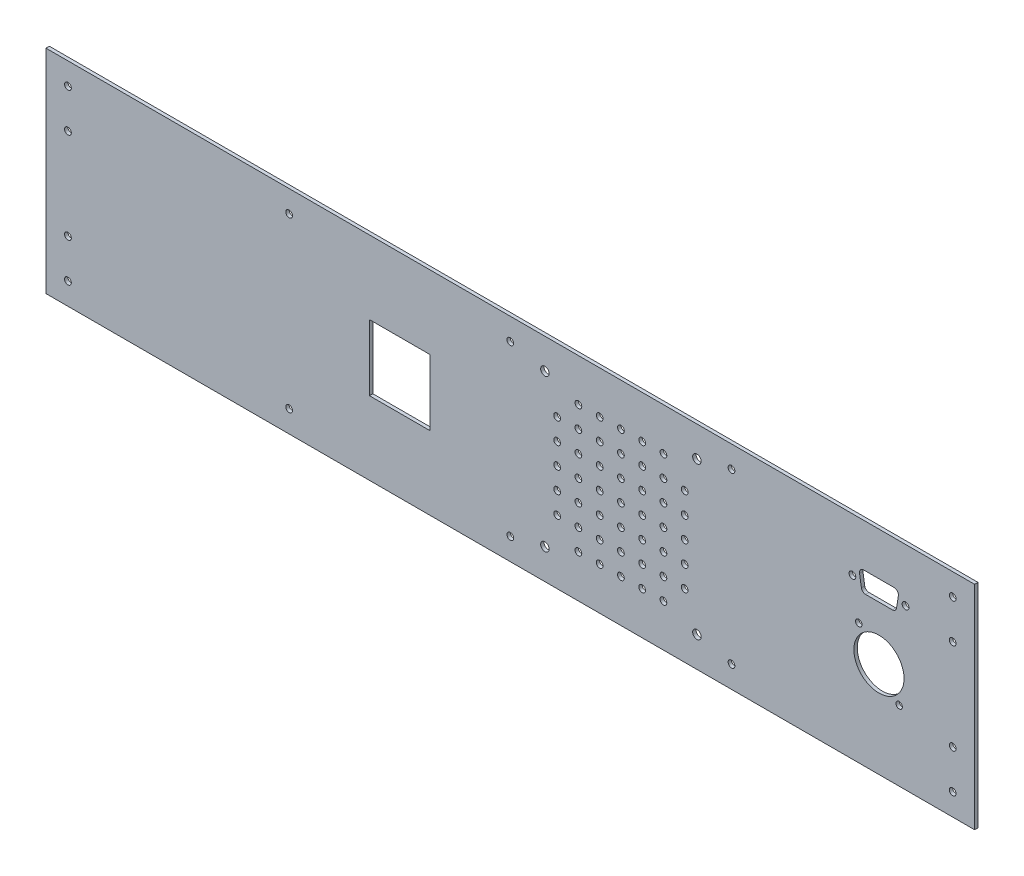
from build123d import *

# Parameters (mm, degrees)
ESQUISSE1_W             = 436.825
ESQUISSE1_H             = 100
BOSS_EXTRU_1_DEPTH      = 1.5875
ENL_V_MAT_EXTRU_1_REACH = 3.587
ESQUISSE2_R             = 1.5875
ENL_V_MAT_EXTRU_2_REACH = 3.587
ESQUISSE3_W             = 28.5
ESQUISSE3_H             = 31
ESQUISSE4_R             = 2
ESQUISSE4_R_2           = 1.5875
ENL_V_MAT_EXTRU_3_DEPTH = 1.5875
ENL_V_MAT_EXTRU_4_REACH = 3.587
ESQUISSE5_R             = 11.8
ESQUISSE5_R_2           = 1.53125
ESQUISSE5_R_3           = 1.5875
CONG_1_R                = 2


with BuildPart() as part:
    # Esquisse1 → Boss.-Extru.1 (new body)
    with BuildSketch(Plane.XY):
        with Locations((98.31082913, 31.147540984)):
            Rectangle(ESQUISSE1_W, ESQUISSE1_H)
    extrude(amount=BOSS_EXTRU_1_DEPTH)

    # Esquisse2 → Enlèv. mat.-Extru.1 (cut, up to next)
    with BuildSketch(Plane(origin=(0, 0, 0), x_dir=(-1, 0, 0), z_dir=(0, 0, -1)), mode=Mode.PRIVATE) as enl_v_mat_extru_1_sk1:
        with Locations((-306.40457913, 9.727540984)):
            Circle(ESQUISSE2_R)
    enl_v_mat_extru_1_tool1 = extrude(enl_v_mat_extru_1_sk1.sketch, amount=-ENL_V_MAT_EXTRU_1_REACH, mode=Mode.PRIVATE) & part.part
    add(enl_v_mat_extru_1_tool1.solids().sort_by_distance((306.404579, 9.727541, 0))[0], mode=Mode.SUBTRACT)
    # Esquisse2 → Enlèv. mat.-Extru.1 (cut, up to next)
    with BuildSketch(Plane(origin=(0, 0, 0), x_dir=(-1, 0, 0), z_dir=(0, 0, -1)), mode=Mode.PRIVATE) as enl_v_mat_extru_1_sk2:
        with Locations((-306.40457913, -8.533709016)):
            Circle(ESQUISSE2_R)
    enl_v_mat_extru_1_tool2 = extrude(enl_v_mat_extru_1_sk2.sketch, amount=-ENL_V_MAT_EXTRU_1_REACH, mode=Mode.PRIVATE) & part.part
    add(enl_v_mat_extru_1_tool2.solids().sort_by_distance((306.404579, -8.533709, 0))[0], mode=Mode.SUBTRACT)
    # Esquisse2 → Enlèv. mat.-Extru.1 (cut, up to next)
    with BuildSketch(Plane(origin=(0, 0, 0), x_dir=(-1, 0, 0), z_dir=(0, 0, -1)), mode=Mode.PRIVATE) as enl_v_mat_extru_1_sk3:
        with Locations((-98.31082913, -8.533709016)):
            Circle(ESQUISSE2_R)
    enl_v_mat_extru_1_tool3 = extrude(enl_v_mat_extru_1_sk3.sketch, amount=-ENL_V_MAT_EXTRU_1_REACH, mode=Mode.PRIVATE) & part.part
    add(enl_v_mat_extru_1_tool3.solids().sort_by_distance((98.310829, -8.533709, 0))[0], mode=Mode.SUBTRACT)
    # Esquisse2 → Enlèv. mat.-Extru.1 (cut, up to next)
    with BuildSketch(Plane(origin=(0, 0, 0), x_dir=(-1, 0, 0), z_dir=(0, 0, -1)), mode=Mode.PRIVATE) as enl_v_mat_extru_1_sk4:
        with Locations((-202.35770413, -8.533709016)):
            Circle(ESQUISSE2_R)
    enl_v_mat_extru_1_tool4 = extrude(enl_v_mat_extru_1_sk4.sketch, amount=-ENL_V_MAT_EXTRU_1_REACH, mode=Mode.PRIVATE) & part.part
    add(enl_v_mat_extru_1_tool4.solids().sort_by_distance((202.357704, -8.533709, 0))[0], mode=Mode.SUBTRACT)
    # Esquisse2 → Enlèv. mat.-Extru.1 (cut, up to next)
    with BuildSketch(Plane(origin=(0, 0, 0), x_dir=(-1, 0, 0), z_dir=(0, 0, -1)), mode=Mode.PRIVATE) as enl_v_mat_extru_1_sk5:
        with Locations((5.73604587, -8.533709016)):
            Circle(ESQUISSE2_R)
    enl_v_mat_extru_1_tool5 = extrude(enl_v_mat_extru_1_sk5.sketch, amount=-ENL_V_MAT_EXTRU_1_REACH, mode=Mode.PRIVATE) & part.part
    add(enl_v_mat_extru_1_tool5.solids().sort_by_distance((-5.736046, -8.533709, 0))[0], mode=Mode.SUBTRACT)
    # Esquisse2 → Enlèv. mat.-Extru.1 (cut, up to next)
    with BuildSketch(Plane(origin=(0, 0, 0), x_dir=(-1, 0, 0), z_dir=(0, 0, -1)), mode=Mode.PRIVATE) as enl_v_mat_extru_1_sk6:
        with Locations((109.78292087, -8.533709016)):
            Circle(ESQUISSE2_R)
    enl_v_mat_extru_1_tool6 = extrude(enl_v_mat_extru_1_sk6.sketch, amount=-ENL_V_MAT_EXTRU_1_REACH, mode=Mode.PRIVATE) & part.part
    add(enl_v_mat_extru_1_tool6.solids().sort_by_distance((-109.782921, -8.533709, 0))[0], mode=Mode.SUBTRACT)
    # Esquisse2 → Enlèv. mat.-Extru.1 (cut, up to next)
    with BuildSketch(Plane(origin=(0, 0, 0), x_dir=(-1, 0, 0), z_dir=(0, 0, -1)), mode=Mode.PRIVATE) as enl_v_mat_extru_1_sk7:
        with Locations((109.78292087, 9.727540984)):
            Circle(ESQUISSE2_R)
    enl_v_mat_extru_1_tool7 = extrude(enl_v_mat_extru_1_sk7.sketch, amount=-ENL_V_MAT_EXTRU_1_REACH, mode=Mode.PRIVATE) & part.part
    add(enl_v_mat_extru_1_tool7.solids().sort_by_distance((-109.782921, 9.727541, 0))[0], mode=Mode.SUBTRACT)
    # Esquisse2 → Enlèv. mat.-Extru.1 (cut, up to next)
    with BuildSketch(Plane(origin=(0, 0, 0), x_dir=(-1, 0, 0), z_dir=(0, 0, -1)), mode=Mode.PRIVATE) as enl_v_mat_extru_1_sk8:
        with Locations((109.78292087, 52.567540984)):
            Circle(ESQUISSE2_R)
    enl_v_mat_extru_1_tool8 = extrude(enl_v_mat_extru_1_sk8.sketch, amount=-ENL_V_MAT_EXTRU_1_REACH, mode=Mode.PRIVATE) & part.part
    add(enl_v_mat_extru_1_tool8.solids().sort_by_distance((-109.782921, 52.567541, 0))[0], mode=Mode.SUBTRACT)
    # Esquisse2 → Enlèv. mat.-Extru.1 (cut, up to next)
    with BuildSketch(Plane(origin=(0, 0, 0), x_dir=(-1, 0, 0), z_dir=(0, 0, -1)), mode=Mode.PRIVATE) as enl_v_mat_extru_1_sk9:
        with Locations((109.78292087, 70.828790984)):
            Circle(ESQUISSE2_R)
    enl_v_mat_extru_1_tool9 = extrude(enl_v_mat_extru_1_sk9.sketch, amount=-ENL_V_MAT_EXTRU_1_REACH, mode=Mode.PRIVATE) & part.part
    add(enl_v_mat_extru_1_tool9.solids().sort_by_distance((-109.782921, 70.828791, 0))[0], mode=Mode.SUBTRACT)
    # Esquisse2 → Enlèv. mat.-Extru.1 (cut, up to next)
    with BuildSketch(Plane(origin=(0, 0, 0), x_dir=(-1, 0, 0), z_dir=(0, 0, -1)), mode=Mode.PRIVATE) as enl_v_mat_extru_1_sk10:
        with Locations((5.73604587, 70.828790984)):
            Circle(ESQUISSE2_R)
    enl_v_mat_extru_1_tool10 = extrude(enl_v_mat_extru_1_sk10.sketch, amount=-ENL_V_MAT_EXTRU_1_REACH, mode=Mode.PRIVATE) & part.part
    add(enl_v_mat_extru_1_tool10.solids().sort_by_distance((-5.736046, 70.828791, 0))[0], mode=Mode.SUBTRACT)
    # Esquisse2 → Enlèv. mat.-Extru.1 (cut, up to next)
    with BuildSketch(Plane(origin=(0, 0, 0), x_dir=(-1, 0, 0), z_dir=(0, 0, -1)), mode=Mode.PRIVATE) as enl_v_mat_extru_1_sk11:
        with Locations((-98.31082913, 70.828790984)):
            Circle(ESQUISSE2_R)
    enl_v_mat_extru_1_tool11 = extrude(enl_v_mat_extru_1_sk11.sketch, amount=-ENL_V_MAT_EXTRU_1_REACH, mode=Mode.PRIVATE) & part.part
    add(enl_v_mat_extru_1_tool11.solids().sort_by_distance((98.310829, 70.828791, 0))[0], mode=Mode.SUBTRACT)
    # Esquisse2 → Enlèv. mat.-Extru.1 (cut, up to next)
    with BuildSketch(Plane(origin=(0, 0, 0), x_dir=(-1, 0, 0), z_dir=(0, 0, -1)), mode=Mode.PRIVATE) as enl_v_mat_extru_1_sk12:
        with Locations((-202.35770413, 70.828790984)):
            Circle(ESQUISSE2_R)
    enl_v_mat_extru_1_tool12 = extrude(enl_v_mat_extru_1_sk12.sketch, amount=-ENL_V_MAT_EXTRU_1_REACH, mode=Mode.PRIVATE) & part.part
    add(enl_v_mat_extru_1_tool12.solids().sort_by_distance((202.357704, 70.828791, 0))[0], mode=Mode.SUBTRACT)
    # Esquisse2 → Enlèv. mat.-Extru.1 (cut, up to next)
    with BuildSketch(Plane(origin=(0, 0, 0), x_dir=(-1, 0, 0), z_dir=(0, 0, -1)), mode=Mode.PRIVATE) as enl_v_mat_extru_1_sk13:
        with Locations((-306.40457913, 70.828790984)):
            Circle(ESQUISSE2_R)
    enl_v_mat_extru_1_tool13 = extrude(enl_v_mat_extru_1_sk13.sketch, amount=-ENL_V_MAT_EXTRU_1_REACH, mode=Mode.PRIVATE) & part.part
    add(enl_v_mat_extru_1_tool13.solids().sort_by_distance((306.404579, 70.828791, 0))[0], mode=Mode.SUBTRACT)
    # Esquisse2 → Enlèv. mat.-Extru.1 (cut, up to next)
    with BuildSketch(Plane(origin=(0, 0, 0), x_dir=(-1, 0, 0), z_dir=(0, 0, -1)), mode=Mode.PRIVATE) as enl_v_mat_extru_1_sk14:
        with Locations((-306.40457913, 52.567540984)):
            Circle(ESQUISSE2_R)
    enl_v_mat_extru_1_tool14 = extrude(enl_v_mat_extru_1_sk14.sketch, amount=-ENL_V_MAT_EXTRU_1_REACH, mode=Mode.PRIVATE) & part.part
    add(enl_v_mat_extru_1_tool14.solids().sort_by_distance((306.404579, 52.567541, 0))[0], mode=Mode.SUBTRACT)

    # Esquisse3 → Enlèv. mat.-Extru.2 (cut, up to next)
    with BuildSketch(Plane(origin=(0, 0, 0), x_dir=(-1, 0, 0), z_dir=(0, 0, -1)), mode=Mode.PRIVATE) as enl_v_mat_extru_2_sk1:
        with Locations((-46.28739163, 31.147540984)):
            Rectangle(ESQUISSE3_W, ESQUISSE3_H)
    enl_v_mat_extru_2_tool1 = extrude(enl_v_mat_extru_2_sk1.sketch, amount=-ENL_V_MAT_EXTRU_2_REACH, mode=Mode.PRIVATE) & part.part
    add(enl_v_mat_extru_2_tool1.solids().sort_by_distance((46.287392, 31.147541, 0))[0], mode=Mode.SUBTRACT)

    # Esquisse4 → Enlèv. mat.-Extru.3 (cut)
    with BuildSketch(Plane(origin=(0, 0, 0), x_dir=(-1, 0, 0), z_dir=(0, 0, -1))):
        with Locations((-186.08426663, 66.897540984)):
            Circle(ESQUISSE4_R)
        with Locations((-114.58426663, 66.897540984)):
            Circle(ESQUISSE4_R)
        with Locations((-114.58426663, -4.602459016)):
            Circle(ESQUISSE4_R)
        with Locations((-186.08426663, -4.602459016)):
            Circle(ESQUISSE4_R)
        with Locations((-150.33426663, 31.147540984)):
            Circle(ESQUISSE4_R_2)
        with Locations((-140.33426663, 31.147540984)):
            Circle(ESQUISSE4_R_2)
        with Locations((-130.33426663, 31.147540984)):
            Circle(ESQUISSE4_R_2)
        with Locations((-120.33426663, 31.147540984)):
            Circle(ESQUISSE4_R_2)
        with Locations((-140.33426663, 41.147540984)):
            Circle(ESQUISSE4_R_2)
        with Locations((-130.33426663, 41.147540984)):
            Circle(ESQUISSE4_R_2)
        with Locations((-120.33426663, 41.147540984)):
            Circle(ESQUISSE4_R_2)
        with Locations((-140.33426663, 51.147540984)):
            Circle(ESQUISSE4_R_2)
        with Locations((-130.33426663, 51.147540984)):
            Circle(ESQUISSE4_R_2)
        with Locations((-120.33426663, 51.147540984)):
            Circle(ESQUISSE4_R_2)
        with Locations((-140.33426663, 61.147540984)):
            Circle(ESQUISSE4_R_2)
        with Locations((-130.33426663, 61.147540984)):
            Circle(ESQUISSE4_R_2)
        with Locations((-160.33426663, 31.147540984)):
            Circle(ESQUISSE4_R_2)
        with Locations((-170.33426663, 31.147540984)):
            Circle(ESQUISSE4_R_2)
        with Locations((-180.33426663, 31.147540984)):
            Circle(ESQUISSE4_R_2)
        with Locations((-160.33426663, 41.147540984)):
            Circle(ESQUISSE4_R_2)
        with Locations((-170.33426663, 41.147540984)):
            Circle(ESQUISSE4_R_2)
        with Locations((-180.33426663, 41.147540984)):
            Circle(ESQUISSE4_R_2)
        with Locations((-160.33426663, 51.147540984)):
            Circle(ESQUISSE4_R_2)
        with Locations((-170.33426663, 51.147540984)):
            Circle(ESQUISSE4_R_2)
        with Locations((-180.33426663, 51.147540984)):
            Circle(ESQUISSE4_R_2)
        with Locations((-160.33426663, 61.147540984)):
            Circle(ESQUISSE4_R_2)
        with Locations((-170.33426663, 61.147540984)):
            Circle(ESQUISSE4_R_2)
        with Locations((-150.33426663, 41.147540984)):
            Circle(ESQUISSE4_R_2)
        with Locations((-150.33426663, 51.147540984)):
            Circle(ESQUISSE4_R_2)
        with Locations((-150.33426663, 61.147540984)):
            Circle(ESQUISSE4_R_2)
        with Locations((-150.33426663, 21.147540984)):
            Circle(ESQUISSE4_R_2)
        with Locations((-140.33426663, 21.147540984)):
            Circle(ESQUISSE4_R_2)
        with Locations((-130.33426663, 21.147540984)):
            Circle(ESQUISSE4_R_2)
        with Locations((-120.33426663, 21.147540984)):
            Circle(ESQUISSE4_R_2)
        with Locations((-140.33426663, 11.147540984)):
            Circle(ESQUISSE4_R_2)
        with Locations((-130.33426663, 11.147540984)):
            Circle(ESQUISSE4_R_2)
        with Locations((-120.33426663, 11.147540984)):
            Circle(ESQUISSE4_R_2)
        with Locations((-140.33426663, 1.147540984)):
            Circle(ESQUISSE4_R_2)
        with Locations((-130.33426663, 1.147540984)):
            Circle(ESQUISSE4_R_2)
        with Locations((-160.33426663, 21.147540984)):
            Circle(ESQUISSE4_R_2)
        with Locations((-170.33426663, 21.147540984)):
            Circle(ESQUISSE4_R_2)
        with Locations((-180.33426663, 21.147540984)):
            Circle(ESQUISSE4_R_2)
        with Locations((-160.33426663, 11.147540984)):
            Circle(ESQUISSE4_R_2)
        with Locations((-170.33426663, 11.147540984)):
            Circle(ESQUISSE4_R_2)
        with Locations((-180.33426663, 11.147540984)):
            Circle(ESQUISSE4_R_2)
        with Locations((-160.33426663, 1.147540984)):
            Circle(ESQUISSE4_R_2)
        with Locations((-170.33426663, 1.147540984)):
            Circle(ESQUISSE4_R_2)
        with Locations((-150.33426663, 11.147540984)):
            Circle(ESQUISSE4_R_2)
        with Locations((-150.33426663, 1.147540984)):
            Circle(ESQUISSE4_R_2)
    extrude(amount=-ENL_V_MAT_EXTRU_3_DEPTH, mode=Mode.SUBTRACT)

    # Esquisse5 → Enlèv. mat.-Extru.4 (cut, up to next)
    with BuildSketch(Plane(origin=(0, 0, 0), x_dir=(-1, 0, 0), z_dir=(0, 0, -1)), mode=Mode.PRIVATE) as enl_v_mat_extru_4_sk1:
        with Locations((-271.72332913, 26.147540984)):
            Circle(ESQUISSE5_R)
    enl_v_mat_extru_4_tool1 = extrude(enl_v_mat_extru_4_sk1.sketch, amount=-ENL_V_MAT_EXTRU_4_REACH, mode=Mode.PRIVATE) & part.part
    add(enl_v_mat_extru_4_tool1.solids().sort_by_distance((271.723329, 26.147541, 0))[0], mode=Mode.SUBTRACT)
    # Esquisse5 → Enlèv. mat.-Extru.4 (cut, up to next)
    with BuildSketch(Plane(origin=(0, 0, 0), x_dir=(-1, 0, 0), z_dir=(0, 0, -1)), mode=Mode.PRIVATE) as enl_v_mat_extru_4_sk2:
        with Locations((-262.22332913, 38.147540984)):
            Circle(ESQUISSE5_R_2)
    enl_v_mat_extru_4_tool2 = extrude(enl_v_mat_extru_4_sk2.sketch, amount=-ENL_V_MAT_EXTRU_4_REACH, mode=Mode.PRIVATE) & part.part
    add(enl_v_mat_extru_4_tool2.solids().sort_by_distance((262.223329, 38.147541, 0))[0], mode=Mode.SUBTRACT)
    # Esquisse5 → Enlèv. mat.-Extru.4 (cut, up to next)
    with BuildSketch(Plane(origin=(0, 0, 0), x_dir=(-1, 0, 0), z_dir=(0, 0, -1)), mode=Mode.PRIVATE) as enl_v_mat_extru_4_sk3:
        with Locations((-281.22332913, 14.147540984)):
            Circle(ESQUISSE5_R_2)
    enl_v_mat_extru_4_tool3 = extrude(enl_v_mat_extru_4_sk3.sketch, amount=-ENL_V_MAT_EXTRU_4_REACH, mode=Mode.PRIVATE) & part.part
    add(enl_v_mat_extru_4_tool3.solids().sort_by_distance((281.223329, 14.147541, 0))[0], mode=Mode.SUBTRACT)
    # Esquisse5 → Enlèv. mat.-Extru.4 (cut, up to next)
    with BuildSketch(Plane(origin=(0, 0, 0), x_dir=(-1, 0, 0), z_dir=(0, 0, -1)), mode=Mode.PRIVATE) as enl_v_mat_extru_4_sk4:
        with Locations((-259.22832913, 56.147540984)):
            Circle(ESQUISSE5_R_3)
    enl_v_mat_extru_4_tool4 = extrude(enl_v_mat_extru_4_sk4.sketch, amount=-ENL_V_MAT_EXTRU_4_REACH, mode=Mode.PRIVATE) & part.part
    add(enl_v_mat_extru_4_tool4.solids().sort_by_distance((259.228329, 56.147541, 0))[0], mode=Mode.SUBTRACT)
    # Esquisse5 → Enlèv. mat.-Extru.4 (cut, up to next)
    with BuildSketch(Plane(origin=(0, 0, 0), x_dir=(-1, 0, 0), z_dir=(0, 0, -1)), mode=Mode.PRIVATE) as enl_v_mat_extru_4_sk5:
        with Locations((-284.21832913, 56.147540984)):
            Circle(ESQUISSE5_R_3)
    enl_v_mat_extru_4_tool5 = extrude(enl_v_mat_extru_4_sk5.sketch, amount=-ENL_V_MAT_EXTRU_4_REACH, mode=Mode.PRIVATE) & part.part
    add(enl_v_mat_extru_4_tool5.solids().sort_by_distance((284.218329, 56.147541, 0))[0], mode=Mode.SUBTRACT)
    # Esquisse5 → Enlèv. mat.-Extru.4 (cut, up to next)
    with BuildSketch(Plane(origin=(0, 0, 0), x_dir=(-1, 0, 0), z_dir=(0, 0, -1)), mode=Mode.PRIVATE) as enl_v_mat_extru_4_sk6:
        Polygon((-262.22332913, 60.897540984), (-281.22332913, 60.897540984), (-279.72332913, 51.397540984), (-263.72332913, 51.397540984), align=None)
    enl_v_mat_extru_4_tool6 = extrude(enl_v_mat_extru_4_sk6.sketch, amount=-ENL_V_MAT_EXTRU_4_REACH, mode=Mode.PRIVATE) & part.part
    add(enl_v_mat_extru_4_tool6.solids().sort_by_distance((271.723329, 56.283255, 0))[0], mode=Mode.SUBTRACT)

    # Congé1
    cong_1_edges = [part.edges().sort_by_distance(p)[0] for p in [
        (262.22332913, 60.897540984, 0.79375),
        (263.72332913, 51.397540984, 0.79375),
        (279.72332913, 51.397540984, 0.79375),
        (281.22332913, 60.897540984, 0.79375),
    ]]
    fillet(cong_1_edges, radius=CONG_1_R)


solid = part.part
